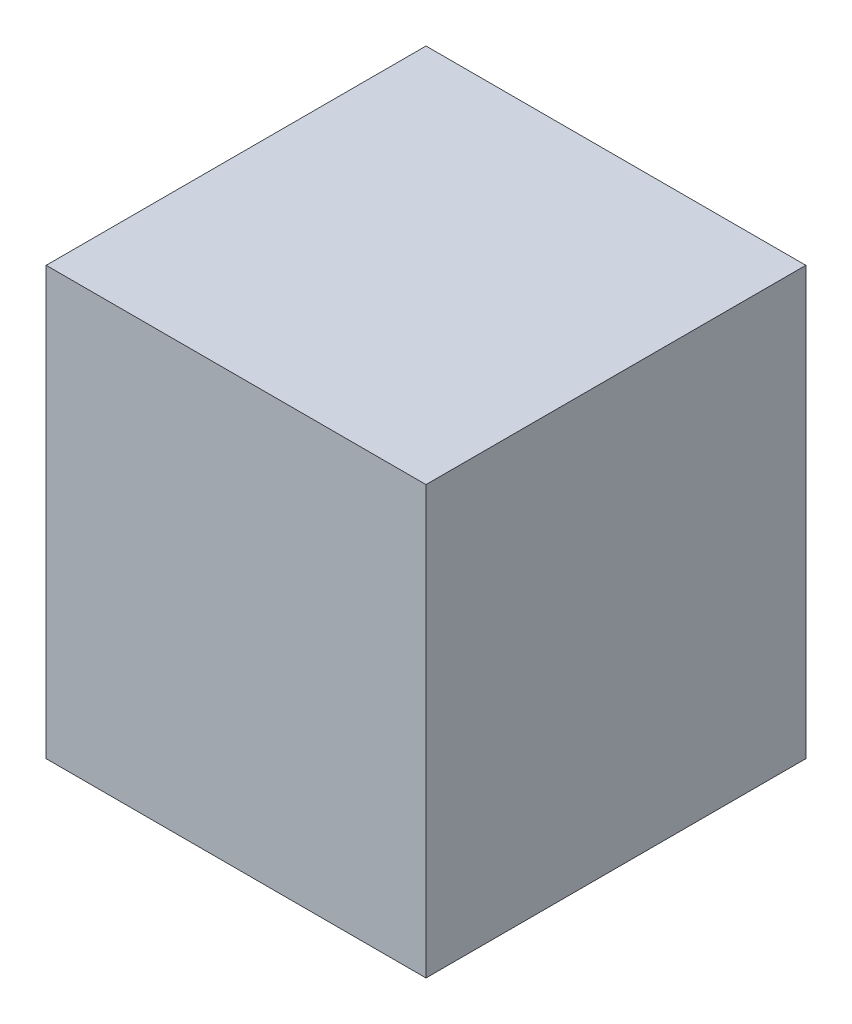
from build123d import *

# Parameters (mm, degrees)
SKETCH1_W      = 80
SKETCH1_H      = 80
EXTRUDE1_DEPTH = 90


with BuildPart() as part:
    # Sketch1 → Extrude1 (new body)
    with BuildSketch(Plane(origin=(0, 0, 0), x_dir=(1, 0, 0), z_dir=(0, 1, 0))):
        with Locations((-40, 40)):
            Rectangle(SKETCH1_W, SKETCH1_H)
    extrude(amount=EXTRUDE1_DEPTH)


solid = part.part
